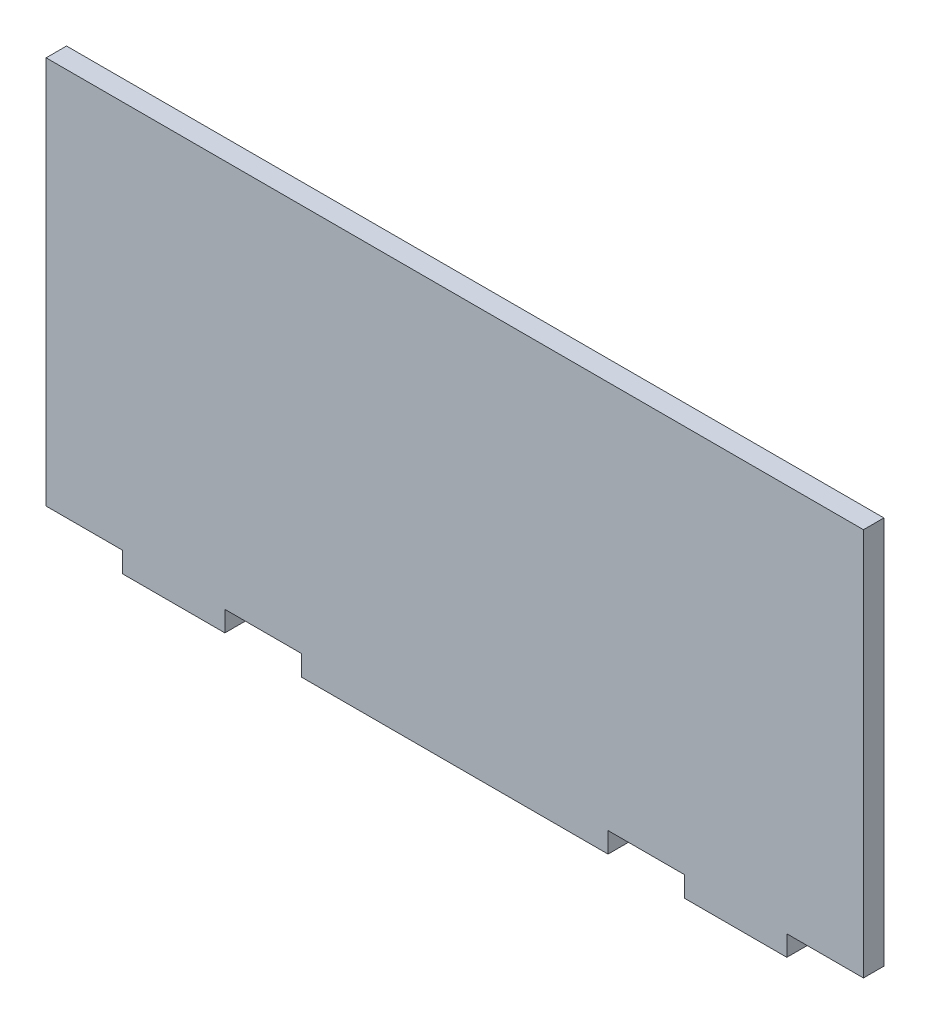
from build123d import *

# Parameters (mm, degrees)
SKETCH1_W           = 203.2
SKETCH1_H           = 101.6
BOSS_EXTRUDE1_DEPTH = 5.08
SKETCH2_W           = 19.05
SKETCH2_H           = 5.08
CUT_EXTRUDE1_DEPTH  = 5.08


with BuildPart() as part:
    # Sketch1 → Boss-Extrude1 (new body)
    with BuildSketch(Plane.XY):
        Rectangle(SKETCH1_W, SKETCH1_H)
    extrude(amount=BOSS_EXTRUDE1_DEPTH)

    # Sketch2 → Cut-Extrude1 (cut)
    with BuildSketch(Plane.XY.offset(5.08)):
        with Locations((-92.075, -48.26)):
            Rectangle(SKETCH2_W, SKETCH2_H)
        with Locations((47.625, -48.26)):
            Rectangle(SKETCH2_W, SKETCH2_H)
        with Locations((92.075, -48.26)):
            Rectangle(SKETCH2_W, SKETCH2_H)
        with Locations((-47.625, -48.26)):
            Rectangle(SKETCH2_W, SKETCH2_H)
    extrude(amount=-CUT_EXTRUDE1_DEPTH, mode=Mode.SUBTRACT)


solid = part.part
